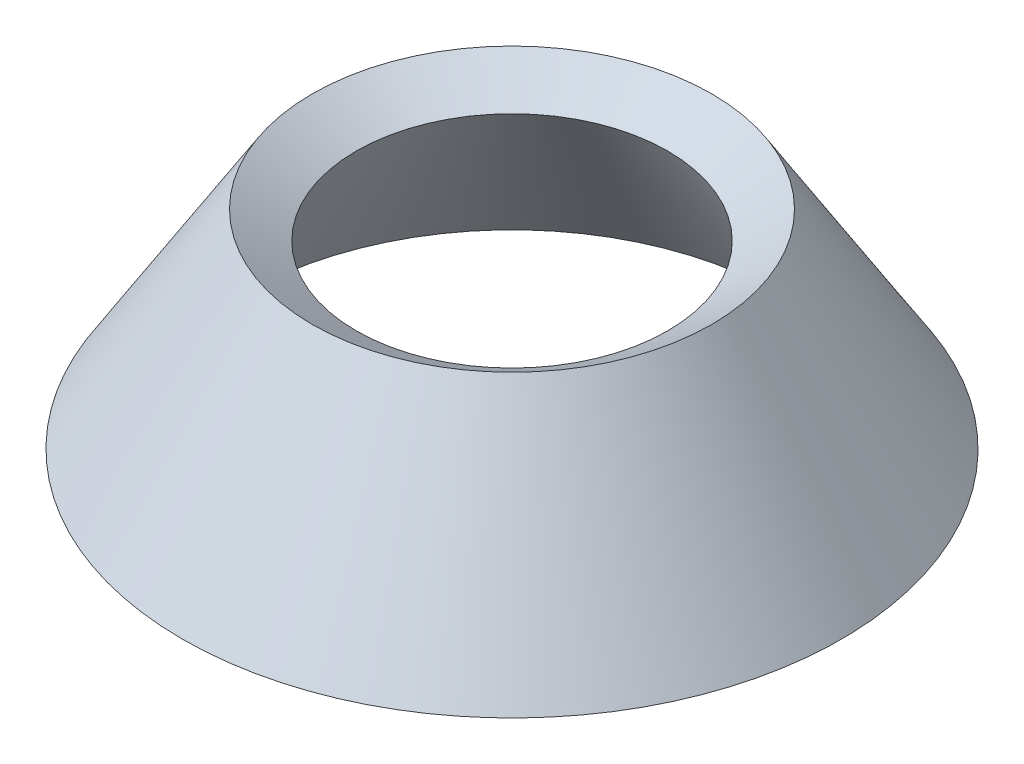
from build123d import *

# Parameters (mm, degrees)
ESQUISSE5_W             = 151.27903366
ESQUISSE5_H             = 142.699955255
ENL_V_MAT_EXTRU_1_DEPTH = 10


with BuildPart() as part:
    # Esquisse1 → Révol.-Mince1 (revolve)
    with BuildSketch(Plane.XY):
        Polygon((55, 0), (30, 40), (38.47998304, 45.2999894), (63.47998304, 5.2999894), align=None)
    revolve(axis=Axis((0, 0, 0), (0, 1, 0)))

    # Esquisse5 → Enlèv. mat.-Extru.1 (cut)
    with BuildSketch(Plane(origin=(0, 5.2999894, 0), x_dir=(1, 0, 0), z_dir=(0, 1, 0))):
        with Locations((-1.064533184, -0.36708692)):
            Rectangle(ESQUISSE5_W, ESQUISSE5_H)
    extrude(amount=-ENL_V_MAT_EXTRU_1_DEPTH, mode=Mode.SUBTRACT)


solid = part.part
